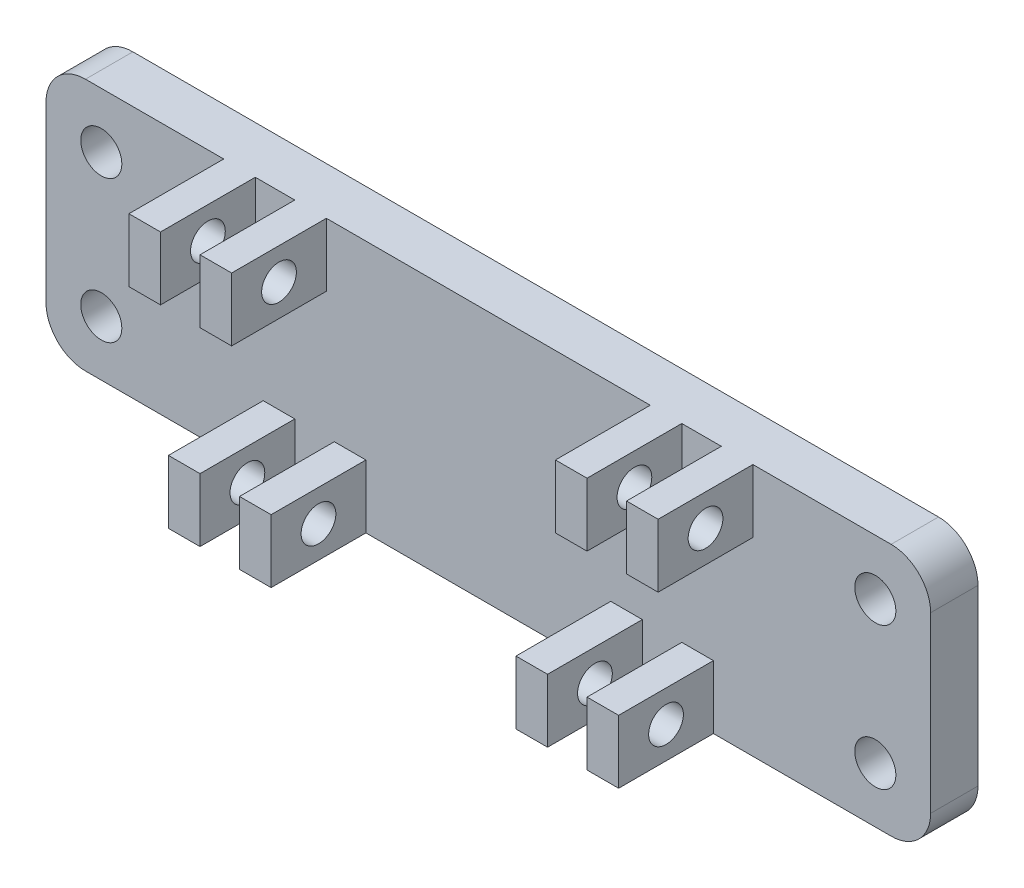
from build123d import *

# Parameters (mm, degrees)
SKETCH_2_R          = 1.3
EXTRUDE_2_DEPTH     = 3
SKETCH_4_W          = 2
SKETCH_4_H          = 4
EXTRUDE_3_DEPTH     = 6
SKETCH_6_R          = 1.1
CUT_EXTRUDE_2_DEPTH = 45.75


with BuildPart() as part:
    # 草图2 → 凸台-拉伸2 (new body)
    with BuildSketch(Plane.XY):
        with BuildLine():
            ThreePointArc((-3.5, -10), (-2.767766953, -11.767766953), (-1, -12.5))
            Line((-1, -12.5), (50, -12.5))
            ThreePointArc((50, -12.5), (51.767766953, -11.767766953), (52.5, -10))
            Line((52.5, -10), (52.5, 1))
            ThreePointArc((52.5, 1), (51.767766953, 2.767766953), (50, 3.5))
            Line((50, 3.5), (-1, 3.5))
            ThreePointArc((-1, 3.5), (-2.767766953, 2.767766953), (-3.5, 1))
            Line((-3.5, 1), (-3.5, -10))
        make_face()
        with Locations((0, -9)):
            Circle(SKETCH_2_R, mode=Mode.SUBTRACT)
        Circle(SKETCH_2_R, mode=Mode.SUBTRACT)
        with Locations((49, -9)):
            Circle(SKETCH_2_R, mode=Mode.SUBTRACT)
        with Locations((49, 0)):
            Circle(SKETCH_2_R, mode=Mode.SUBTRACT)
    extrude(amount=EXTRUDE_2_DEPTH)

    # 草图4 → 凸台-拉伸3 (add)
    with BuildSketch(Plane.XY.offset(3)):
        with Locations((8.75, 1.5)):
            Rectangle(SKETCH_4_W, SKETCH_4_H)
        with Locations((13.25, 1.5)):
            Rectangle(SKETCH_4_W, SKETCH_4_H)
        with Locations((35.75, 1.5)):
            Rectangle(SKETCH_4_W, SKETCH_4_H)
        with Locations((40.25, 1.5)):
            Rectangle(SKETCH_4_W, SKETCH_4_H)
        with Locations((11.25, -10.5)):
            Rectangle(SKETCH_4_W, SKETCH_4_H)
        with Locations((15.75, -10.5)):
            Rectangle(SKETCH_4_W, SKETCH_4_H)
        with Locations((33.25, -10.5)):
            Rectangle(SKETCH_4_W, SKETCH_4_H)
        with Locations((37.75, -10.5)):
            Rectangle(SKETCH_4_W, SKETCH_4_H)
    extrude(amount=EXTRUDE_3_DEPTH)

    # 草图6 → 切除-拉伸2 (cut, through all)
    with BuildSketch(Plane.ZY.offset(-7.75)):
        with Locations((6, 1.5)):
            Circle(SKETCH_6_R)
        with Locations((6, -10.5)):
            Circle(SKETCH_6_R)
    extrude(amount=-CUT_EXTRUDE_2_DEPTH, mode=Mode.SUBTRACT)


solid = part.part
